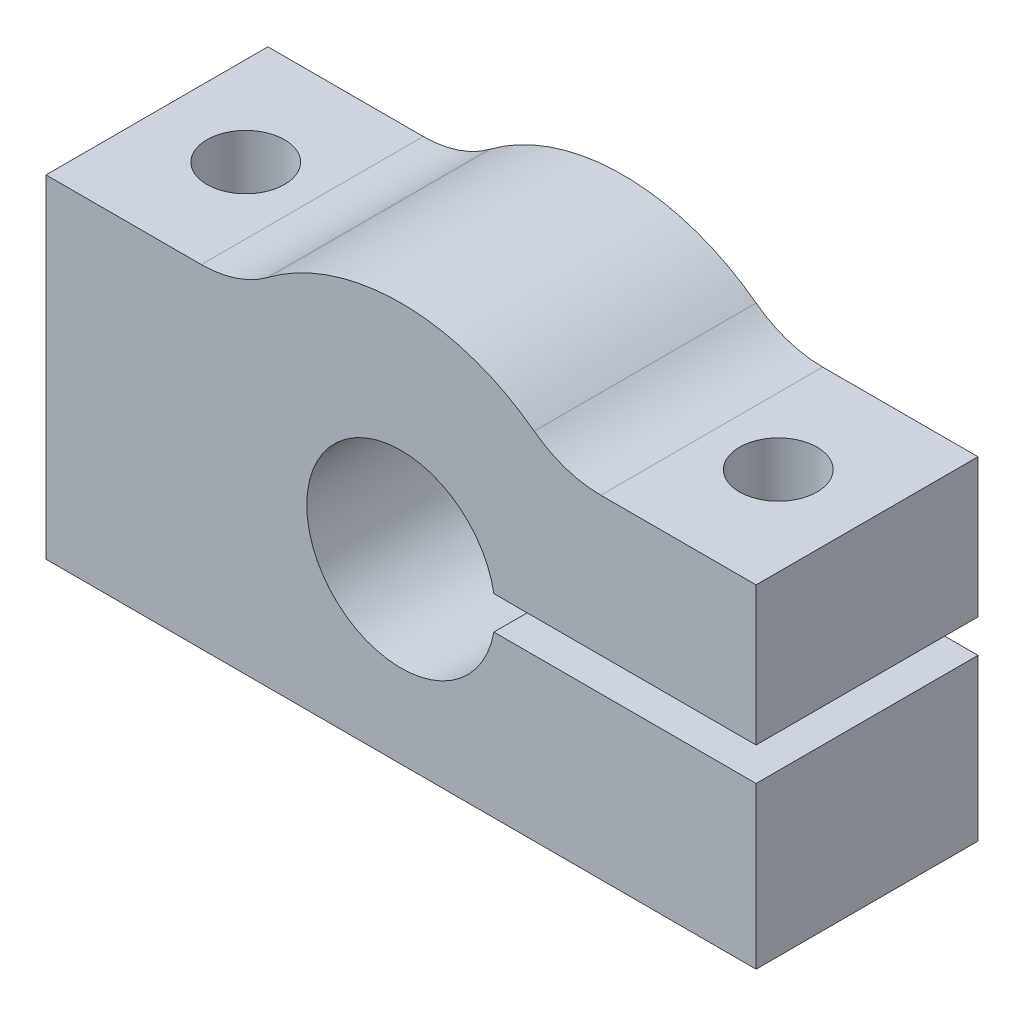
from build123d import *

# Parameters (mm, degrees)
SALIENTE_EXTRUIR1_DEPTH      = 5
SALIENTE_EXTRUIR1_DEPTH_BACK = 5
CROQUIS6_R                   = 1.75
CORTAR_EXTRUIR4_DEPTH        = 25.596747752
REDONDEO1_R                  = 5


with BuildPart() as part:
    # Croquis1 → Saliente-Extruir1 (new, two sides: drawn at the far end of the back side and taken through both)
    with BuildSketch(Plane.XY.offset(-SALIENTE_EXTRUIR1_DEPTH_BACK)):
        with BuildLine():
            Line((4.183300133, 8.75), (16, 8.75))
            Line((16, 8.75), (16, 15))
            Line((16, 15), (7.141428429, 15))
            ThreePointArc((7.141428429, 15), (0, 18), (-7.141428429, 15))
            Line((-7.141428429, 15), (-16, 15))
            Line((-16, 15), (-16, 0))
            Line((-16, 0), (16, 0))
            Line((16, 0), (16, 7.25))
            Line((16, 7.25), (4.183300133, 7.25))
            ThreePointArc((4.183300133, 7.25), (-4.25, 8), (4.183300133, 8.75))
        make_face()
    extrude(amount=SALIENTE_EXTRUIR1_DEPTH + SALIENTE_EXTRUIR1_DEPTH_BACK)

    # Croquis6 → Cortar-Extruir4 (cut, through all)
    with BuildSketch(Plane.XZ):
        with Locations((-12, 0)):
            Circle(CROQUIS6_R)
        with Locations((12, 0)):
            Circle(CROQUIS6_R)
    extrude(amount=-CORTAR_EXTRUIR4_DEPTH, mode=Mode.SUBTRACT)

    # Redondeo1
    redondeo1_edges = [part.edges().sort_by_distance(p)[0] for p in [
        (-7.141428429, 15, 0),
        (7.141428429, 15, 0),
    ]]
    fillet(redondeo1_edges, radius=REDONDEO1_R)


solid = part.part
